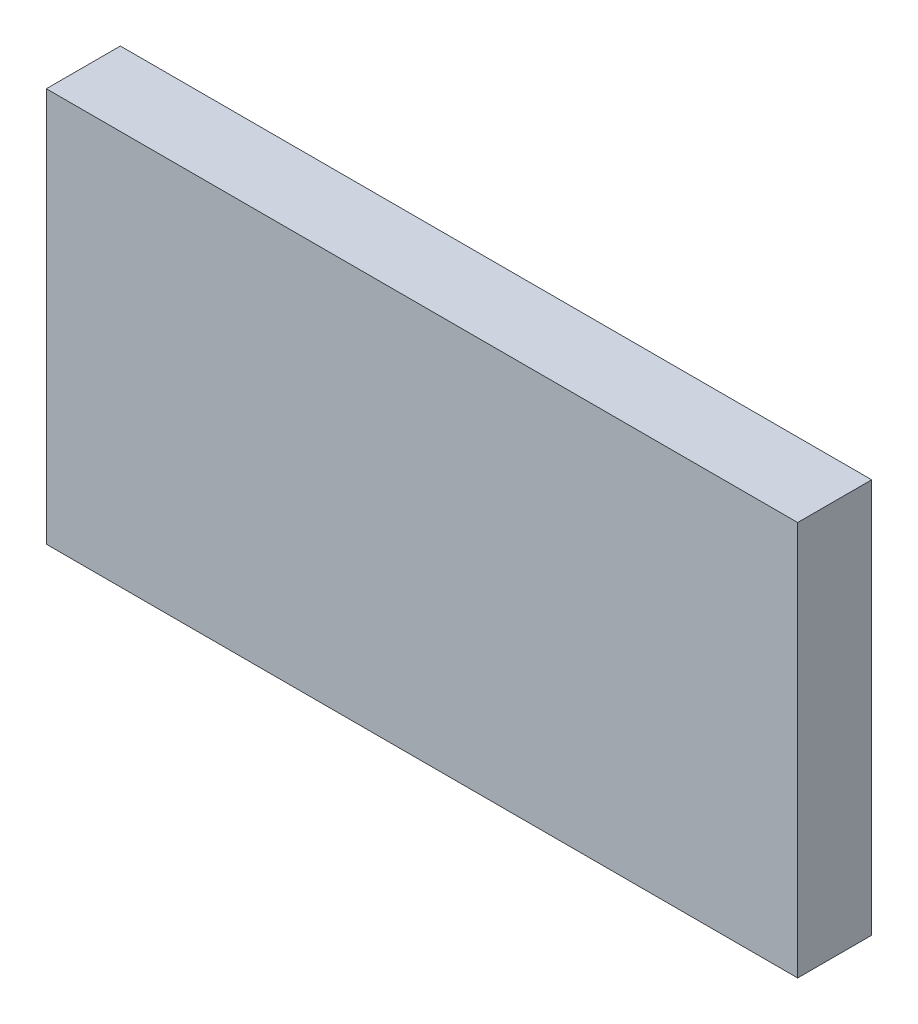
from build123d import *

# Parameters (mm, degrees)
ESQUISSE1_W        = 101.52
ESQUISSE1_H        = 53.3
BOSS_EXTRU_1_DEPTH = 10


with BuildPart() as part:
    # Esquisse1 → Boss.-Extru.1 (new body)
    with BuildSketch(Plane.XY):
        Rectangle(ESQUISSE1_W, ESQUISSE1_H)
    extrude(amount=BOSS_EXTRU_1_DEPTH)


solid = part.part
